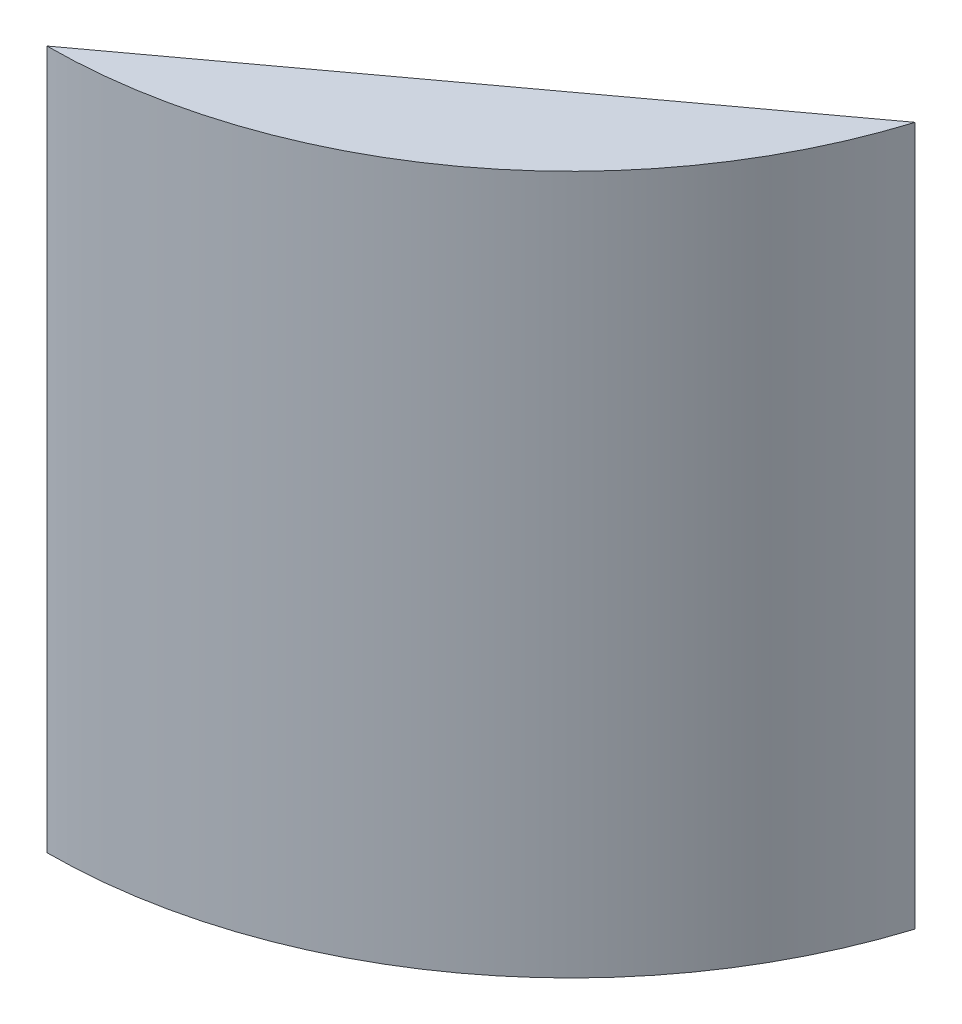
from build123d import *

# Parameters (mm, degrees)
SKETCH1_R           = 85.725
BOSS_EXTRUDE1_DEPTH = 114.3
CUT_EXTRUDE1_DEPTH  = 152.4
SKETCH3_R           = 2.778125
CUT_EXTRUDE2_DEPTH  = 3.175
SKETCH4_R           = 5.588
CUT_EXTRUDE3_DEPTH  = 6.096


with BuildPart() as part:
    # Sketch1 → Boss-Extrude1 (new body)
    with BuildSketch(Plane(origin=(0, 0, 0), x_dir=(1, 0, 0), z_dir=(0, 1, 0))):
        Circle(SKETCH1_R)
    extrude(amount=BOSS_EXTRUDE1_DEPTH)

    # Sketch2 → Cut-Extrude1 (cut)
    with BuildSketch(Plane(origin=(0, 114.3, 0), x_dir=(1, 0, 0), z_dir=(0, 1, 0))):
        Polygon((0, -85.725), (81.83903771, -25.517592593), (151.304734273, 75.062868172), (-38.51393236, 115.934796391), (-149.339737724, 18.86396687), (-68.774879215, -104.537816407), align=None)
    extrude(amount=-CUT_EXTRUDE1_DEPTH, mode=Mode.SUBTRACT)

    # Sketch3 → Cut-Extrude2 (cut)
    with BuildSketch(Plane(origin=(40.919518855, 0, 55.621296296), x_dir=(-0.80550234, 0, 0.592592593), z_dir=(-0.592592593, 0, -0.80550234))):
        with Locations((-36.83, 95.758)):
            Circle(SKETCH3_R)
        with Locations((11.176, 95.758)):
            Circle(SKETCH3_R)
        with Locations((-36.83, 70.358)):
            Circle(SKETCH3_R)
        with Locations((11.176, 70.358)):
            Circle(SKETCH3_R)
        with Locations((-36.83, 51.308)):
            Circle(SKETCH3_R)
        with Locations((6.096, 51.308)):
            Circle(SKETCH3_R)
        with Locations((-36.83, 30.48)):
            Circle(SKETCH3_R)
        with Locations((6.096, 30.48)):
            Circle(SKETCH3_R)
    extrude(amount=-CUT_EXTRUDE2_DEPTH, mode=Mode.SUBTRACT)

    # Sketch4 → Cut-Extrude3 (cut)
    with BuildSketch(Plane(origin=(0, 0, 0), x_dir=(-1, 0, 0), z_dir=(0, -1, 0))):
        with Locations((-45.859759427, -62.336492182)):
            Circle(SKETCH4_R)
    extrude(amount=-CUT_EXTRUDE3_DEPTH, mode=Mode.SUBTRACT)


solid = part.part
